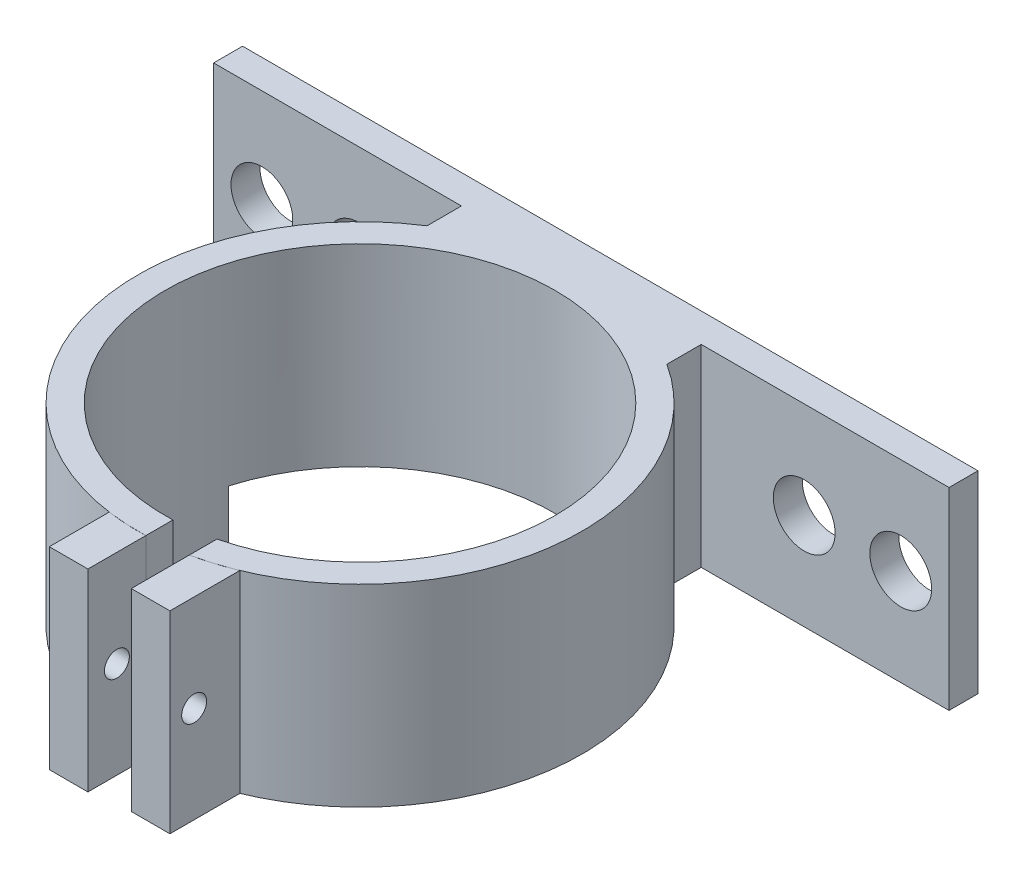
from build123d import *

# Parameters (mm, degrees)
SKETCH1_R            = 11.5
BOSS_EXTRUDE1_DEPTH  = 10
SKETCH5_R            = 10.1
CUT_EXTRUDE3_DEPTH   = 10
SKETCH6_W            = 2
SKETCH6_H            = 5.503378154
CUT_EXTRUDE4_DEPTH   = 10
BOSS_EXTRUDE2_DEPTH  = 10
BOSS_EXTRUDE4_DEPTH  = 10
SKETCH12_R           = 0.645
CUT_EXTRUDE5_DEPTH   = 10
BOSS_EXTRUDE7_DEPTH  = 6
SKETCH17_W           = 4
SKETCH17_H           = 8
BOSS_EXTRUDE8_DEPTH  = 2
SKETCH18_R           = 1.4
CUT_EXTRUDE7_DEPTH   = 2
SKETCH20_W           = 20
SKETCH20_H           = 1.5
BOSS_EXTRUDE10_DEPTH = 10
SKETCH26_R           = 1.6
CUT_EXTRUDE14_DEPTH  = 10
SKETCH27_R           = 1.6
CUT_EXTRUDE15_DEPTH  = 2
BOSS_EXTRUDE11_DEPTH = 10


with BuildPart() as part:
    # Sketch1 → Boss-Extrude1 (new body)
    with BuildSketch(Plane(origin=(0, 0, 0), x_dir=(1, 0, 0), z_dir=(0, 1, 0))):
        Circle(SKETCH1_R)
    extrude(amount=BOSS_EXTRUDE1_DEPTH)

    # Sketch5 → Cut-Extrude3 (cut)
    with BuildSketch(Plane(origin=(0, 10, 0), x_dir=(1, 0, 0), z_dir=(0, 1, 0))):
        Circle(SKETCH5_R)
    extrude(amount=-CUT_EXTRUDE3_DEPTH, mode=Mode.SUBTRACT)

    # Sketch6 → Cut-Extrude4 (cut)
    with BuildSketch(Plane(origin=(0, 10, 0), x_dir=(1, 0, 0), z_dir=(0, 1, 0))):
        with Locations((1.400327363, -10.002453863)):
            Rectangle(SKETCH6_W, SKETCH6_H)
    extrude(amount=-CUT_EXTRUDE4_DEPTH, mode=Mode.SUBTRACT)

    # Sketch16 → Boss-Extrude7 (add)
    with BuildSketch(Plane.XZ):
        with BuildLine():
            Line((-10.148583893, 5.132702821), (-8.698583893, 5.132702821))
            ThreePointArc((-8.698583893, 5.132702821), (-10.02417081, 1.235313551), (-9.684451811, -2.867297179))
            Line((-9.684451811, -2.867297179), (-11.136813139, -2.867297179))
            ThreePointArc((-11.136813139, -2.867297179), (-11.482501921, 1.236442607), (-10.148583893, 5.132702821))
        make_face()
    extrude(amount=BOSS_EXTRUDE7_DEPTH)

    # Sketch17 → Boss-Extrude8 (add)
    with BuildSketch(Plane.XZ.offset(6)):
        with Locations((-8.410632475, 1.132702821)):
            Rectangle(SKETCH17_W, SKETCH17_H)
    extrude(amount=-BOSS_EXTRUDE8_DEPTH)

    # Sketch18 → Cut-Extrude7 (cut)
    with BuildSketch(Plane.XZ.offset(6)):
        with Locations((-8.410632475, 1.132702821)):
            Circle(SKETCH18_R)
    extrude(amount=-CUT_EXTRUDE7_DEPTH, mode=Mode.SUBTRACT)

    # Sketch20 → Boss-Extrude10 (add)
    with BuildSketch(Plane.XZ):
        with Locations((9.041954101, -12.210023912)):
            Rectangle(SKETCH20_W, SKETCH20_H)
    boss_extrude10 = extrude(amount=-BOSS_EXTRUDE10_DEPTH)

    # Mirror1: Boss-Extrude10 across plane
    add(boss_extrude10.mirror(Plane(origin=(0, 0, 0), x_dir=(0, 0, 1), z_dir=(1, 0, 0))))

    # Sketch26 → Cut-Extrude14 (cut)
    with BuildSketch(Plane(origin=(0, 0, -12.960023912), x_dir=(-1, 0, 0), z_dir=(0, 0, -1))):
        with Locations((-16.541954101, 5)):
            Circle(SKETCH26_R)
    cut_extrude14 = extrude(amount=-CUT_EXTRUDE14_DEPTH, mode=Mode.SUBTRACT)

    # Mirror2: Cut-Extrude14 across plane
    add(cut_extrude14.mirror(Plane(origin=(0, 0, 0), x_dir=(0, 0, 1), z_dir=(1, 0, 0))), mode=Mode.SUBTRACT)

    # Sketch27 → Cut-Extrude15 (cut)
    with BuildSketch(Plane(origin=(0, 0, -12.960023912), x_dir=(-1, 0, 0), z_dir=(0, 0, -1))):
        with Locations((-11.541954101, 5)):
            Circle(SKETCH27_R)
    cut_extrude15 = extrude(amount=-CUT_EXTRUDE15_DEPTH, mode=Mode.SUBTRACT)

    # Mirror3: Cut-Extrude15 across plane
    add(cut_extrude15.mirror(Plane(origin=(0, 0, 0), x_dir=(0, 0, 1), z_dir=(1, 0, 0))), mode=Mode.SUBTRACT)

    # Sketch28 → Boss-Extrude11 (add)
    with BuildSketch(Plane.XZ):
        Polygon((0, -11.441867229), (-6.20955334, -9.137290732), (-6.20955334, -12.338091423), align=None)
    boss_extrude11 = extrude(amount=-BOSS_EXTRUDE11_DEPTH)

    # Mirror4: Boss-Extrude11 across plane
    add(boss_extrude11.mirror(Plane(origin=(0, 0, 0), x_dir=(0, 0, 1), z_dir=(1, 0, 0))))


with BuildPart() as body_2:
    # Sketch7 → Boss-Extrude2 (new body)
    with BuildSketch(Plane(origin=(0.400327363, 10, 11.493029975), x_dir=(1, 0, 0), z_dir=(0, 1, 0))):
        with BuildLine():
            Line((-2, 0.104832248), (-2, -3))
            Line((-2, -3), (0, -3))
            Line((0, -3), (0, 0))
            ThreePointArc((0, 0), (-1.002286433, 0.008795334), (-2, 0.104832248))
        make_face()
    extrude(amount=-BOSS_EXTRUDE2_DEPTH)


with BuildPart() as body_3:
    # Sketch11 → Boss-Extrude4 (new body)
    with BuildSketch(Plane(origin=(0, 10, 0), x_dir=(1, 0, 0), z_dir=(0, 1, 0))):
        with BuildLine():
            Line((4.400327363, -14.246707454), (4.400327363, -10.624835015))
            ThreePointArc((4.400327363, -10.624835015), (3.414514242, -10.981397565), (2.400327363, -11.246707454))
            Line((2.400327363, -11.246707454), (2.400327363, -14.246707454))
            Line((2.400327363, -14.246707454), (4.400327363, -14.246707454))
        make_face()
    extrude(amount=-BOSS_EXTRUDE4_DEPTH)


with BuildPart() as cut_extrude5_tool:
    # Sketch12 → Cut-Extrude5 (new body)
    with BuildSketch(Plane.ZY.offset(1.599672637)):
        with Locations((12.993029975, 5)):
            Circle(SKETCH12_R)
    extrude(amount=-CUT_EXTRUDE5_DEPTH)


with BuildPart() as body_2_1:
    add(body_2.part)

    # Cut-Extrude5: cut by cut_extrude5_tool
    add(cut_extrude5_tool.part, mode=Mode.SUBTRACT)


with BuildPart() as body_3_1:
    add(body_3.part)

    # Cut-Extrude5: cut by cut_extrude5_tool
    add(cut_extrude5_tool.part, mode=Mode.SUBTRACT)


solid = Compound([part.part, body_2_1.part, body_3_1.part])
